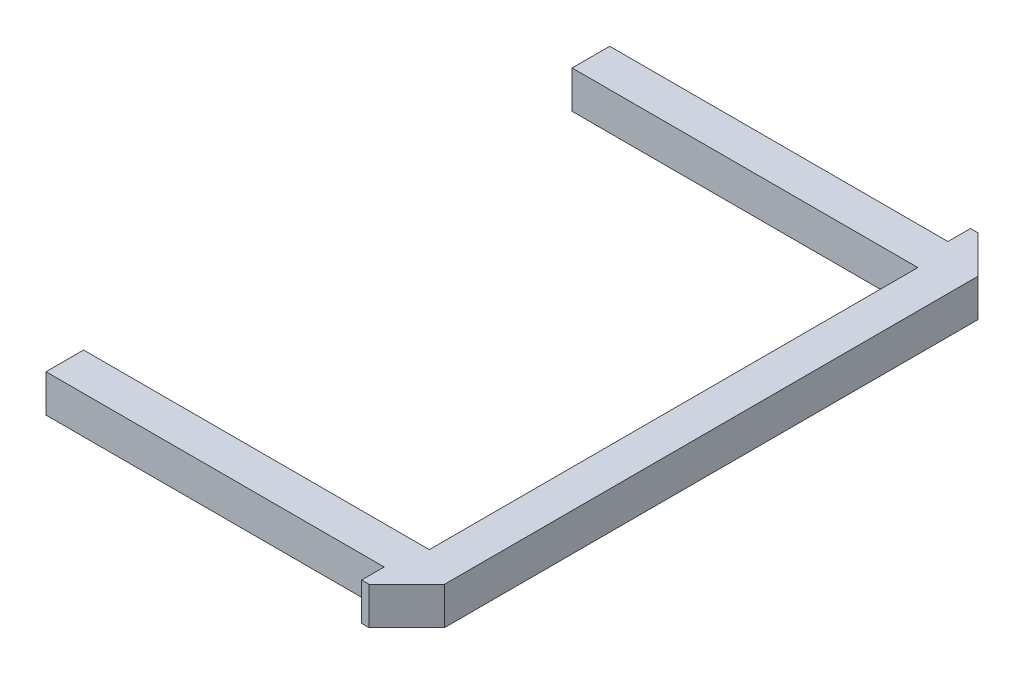
from build123d import *

# Parameters (mm, degrees)
BOSS_EXTRUDE1_DEPTH = 5


with BuildPart() as part:
    # Sketch1 → Boss-Extrude1 (new body)
    with BuildSketch(Plane(origin=(0, 0, 0), x_dir=(1, 0, 0), z_dir=(0, 1, 0))):
        Polygon((38.277103845, -125.655523587), (83.277103845, -125.655523587), (83.277103845, -122.655523587), (84.277103845, -122.655523587), (89.277103845, -127.655523587), (89.277103845, -198.655523587), (84.277103845, -203.655523587), (83.277103845, -203.655523587), (83.277103845, -200.655523587), (38.277103845, -200.655523587), (38.277103845, -195.655523587), (84.277103845, -195.655523587), (84.277103845, -130.655523587), (38.277103845, -130.655523587), align=None)
    extrude(amount=BOSS_EXTRUDE1_DEPTH)


solid = part.part
